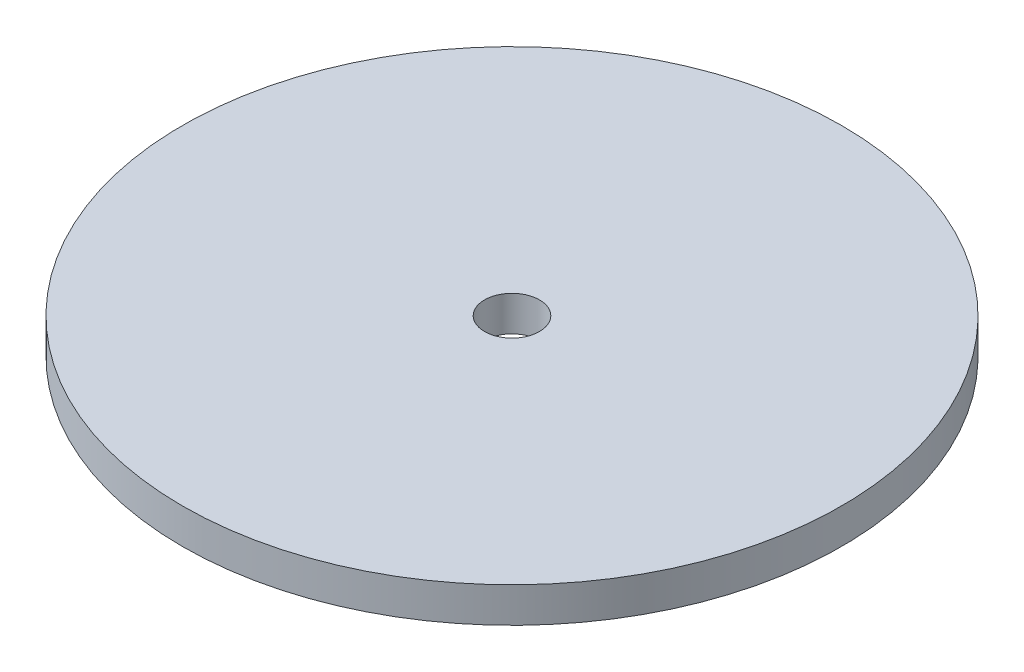
from build123d import *

# Parameters (mm, degrees)
SKETCH1_R           = 38.1
SKETCH1_R_2         = 3.175
BOSS_EXTRUDE1_DEPTH = 4.064


with BuildPart() as part:
    # Sketch1 → Boss-Extrude1 (new body)
    with BuildSketch(Plane(origin=(0, 0, 0), x_dir=(1, 0, 0), z_dir=(0, 1, 0))):
        Circle(SKETCH1_R)
        Circle(SKETCH1_R_2, mode=Mode.SUBTRACT)
    extrude(amount=BOSS_EXTRUDE1_DEPTH)


solid = part.part
